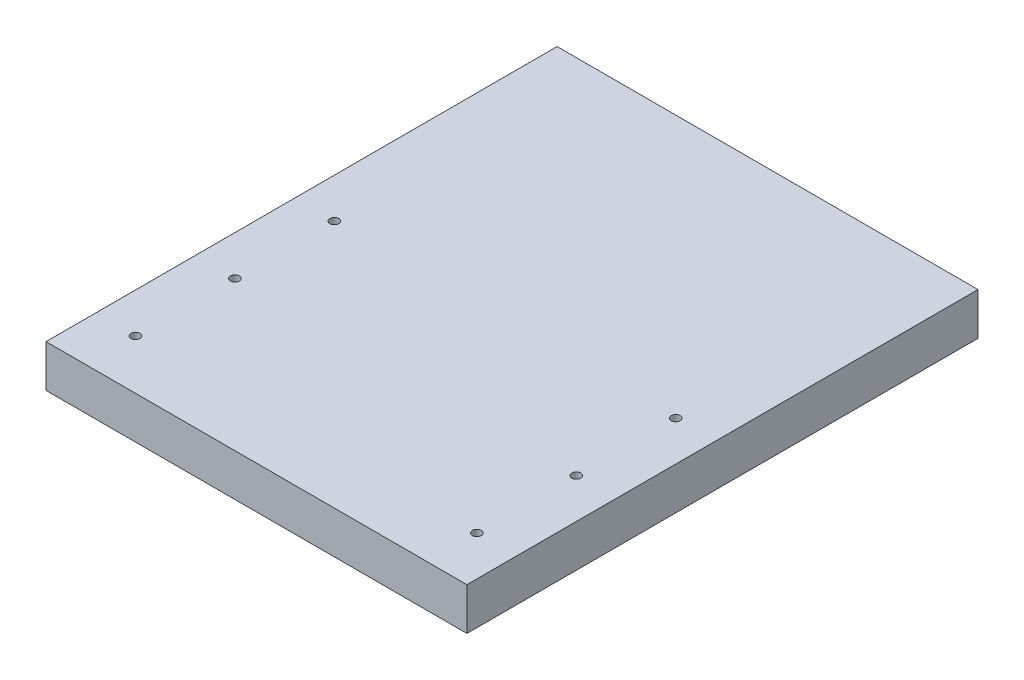
from build123d import *

# Parameters (mm, degrees)
SKETCH1_W           = 127
SKETCH1_H           = 154.21
BOSS_EXTRUDE1_DEPTH = 12.75
SKETCH2_R           = 1.35
CUT_EXTRUDE1_DEPTH  = 13.75


with BuildPart() as part:
    # Sketch1 → Boss-Extrude1 (new body)
    with BuildSketch(Plane(origin=(0, 0, 0), x_dir=(1, 0, 0), z_dir=(0, 1, 0))):
        with Locations((63.5, 77.105)):
            Rectangle(SKETCH1_W, SKETCH1_H)
    extrude(amount=BOSS_EXTRUDE1_DEPTH)

    # Sketch2 → Cut-Extrude1 (cut, through all)
    with BuildSketch(Plane(origin=(0, 12.75, 0), x_dir=(1, 0, 0), z_dir=(0, 1, 0))):
        with Locations((12, 15)):
            Circle(SKETCH2_R)
        with Locations((115, 15)):
            Circle(SKETCH2_R)
        with Locations((115, 45)):
            Circle(SKETCH2_R)
        with Locations((12, 45)):
            Circle(SKETCH2_R)
        with Locations((12, 75)):
            Circle(SKETCH2_R)
        with Locations((115, 75)):
            Circle(SKETCH2_R)
    extrude(amount=-CUT_EXTRUDE1_DEPTH, mode=Mode.SUBTRACT)


solid = part.part
